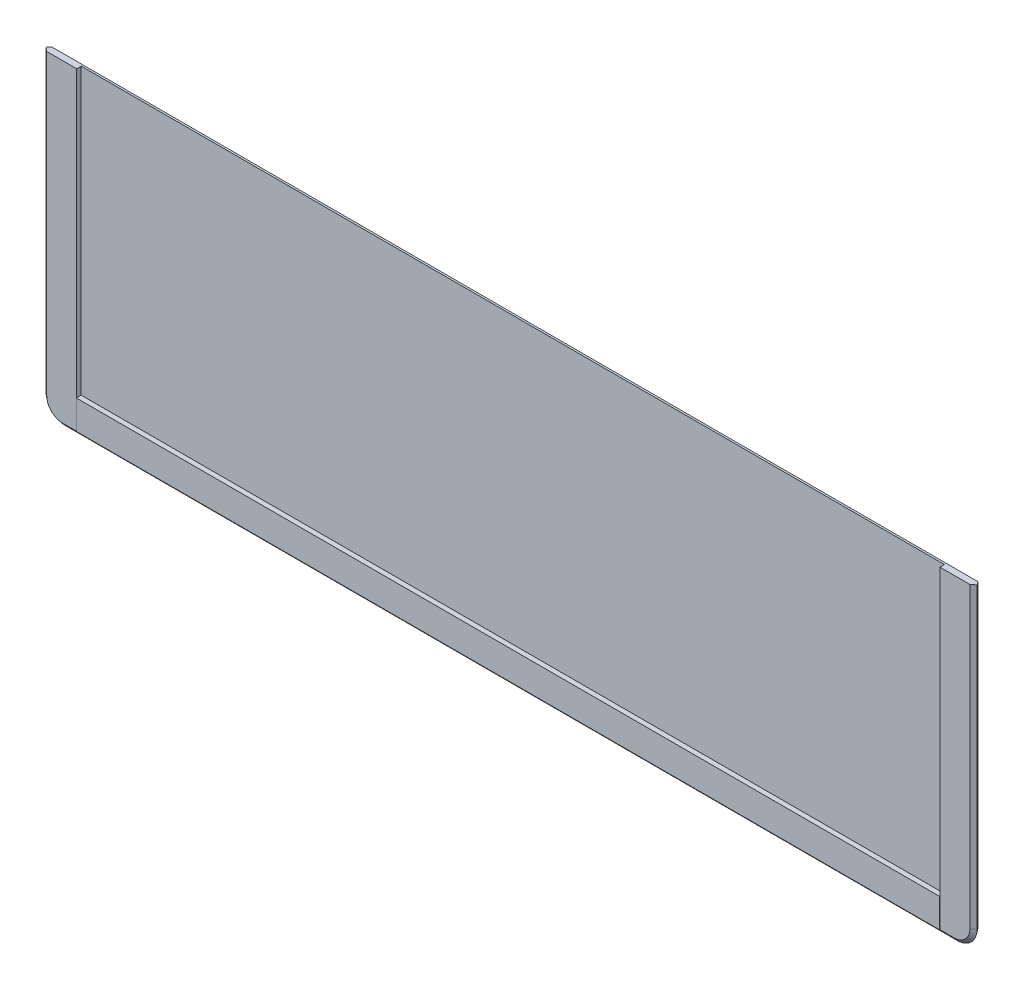
from build123d import *

# Parameters (mm, degrees)
BOSS_EXTRU_1_DEPTH      = 2
ENL_V_MAT_EXTRU_1_DEPTH = 1.4
ESQUISSE10_W            = 267.242852503
ESQUISSE10_H            = 8.975920375
BOSS_EXTRU_3_DEPTH      = 0.1
ESQUISSE11_W            = 12.5
ESQUISSE11_H            = 12.5
ENL_V_MAT_EXTRU_2_DEPTH = 0.1


with BuildPart() as part:
    # Esquisse1 → Boss.-Extru.1 (new body)
    with BuildSketch(Plane.XY):
        with BuildLine():
            Line((-154.451069542, 0), (-154.451069542, -92.3))
            ThreePointArc((-154.451069542, -92.3), (-152.107923791, -97.956854249), (-146.451069542, -100.3))
            Line((-146.451069542, -100.3), (129.548930458, -100.3))
            ThreePointArc((129.548930458, -100.3), (135.205784708, -97.956854249), (137.548930458, -92.3))
            Line((137.548930458, -92.3), (137.548930458, 0))
            Line((137.548930458, 0), (-154.451069542, 0))
        make_face()
    extrude(amount=BOSS_EXTRU_1_DEPTH)

    # Enlèvement de matière-Balayage3: sweep along a path in Esquisse3
    with BuildLine(Plane(origin=(0, 0, 0), x_dir=(-1, 0, 0), z_dir=(0, 0, -1))) as enl_vement_de_mati_re_balayage3_path:
        Line((154.451069542, 0.2), (154.451069542, -92.3))
        ThreePointArc((154.451069542, -92.3), (152.107923791, -97.956854249), (146.451069542, -100.3))
        Line((146.451069542, -100.3), (-129.548930458, -100.3))
        ThreePointArc((-129.548930458, -100.3), (-135.205784708, -97.956854249), (-137.548930458, -92.3))
        Line((-137.548930458, -92.3), (-137.548930458, 0.2))
    # Esquisse9 → Enlèvement de matière-Balayage3 (sweep, cut)
    with BuildSketch(Plane(origin=(0, 0, 0), x_dir=(1, 0, 0), z_dir=(0, 1, 0))):
        with BuildLine():
            Line((135.67035671, -1), (134.446277084, -2))
            Line((134.446277084, -2), (136.182569378, -2))
            Line((136.182569378, -2), (147.673144552, -2))
            Line((147.673144552, -2), (147.673144552, 0))
            Line((147.673144552, 0), (134.956411872, 0))
            add(Edge.make_bspline(
                [(134.956411872, 0), (135.206323755, -0.279338228), (135.44542126, -0.617312994), (135.67035671, -1)],
                knots=[0, 0, 0, 0, 0.17887146, 0.17887146, 0.17887146, 0.17887146], degree=3))
        make_face()
    sweep(path=enl_vement_de_mati_re_balayage3_path.line, mode=Mode.SUBTRACT)

    # Esquisse5 → Enlèv. mat.-Extru.1 (cut)
    with BuildSketch(Plane.XY.offset(2)):
        with BuildLine():
            Line((124.926952048, -84.47802159), (124.926952048, 0))
            Line((124.926952048, 0), (-141.829091132, 0))
            Line((-141.829091132, 0), (-141.829091132, -84.47802159))
            ThreePointArc((-141.829091132, -84.47802159), (-140.950411475, -86.599341934), (-138.829091132, -87.47802159))
            Line((-138.829091132, -87.47802159), (121.926952048, -87.47802159))
            ThreePointArc((121.926952048, -87.47802159), (124.048272392, -86.599341934), (124.926952048, -84.47802159))
        make_face()
        with BuildLine():
            Line((-142.072495793, -88.221426251), (125.17035671, -88.221426251))
            Line((125.17035671, -88.221426251), (125.17035671, 0))
            Line((125.17035671, 0), (124.926952048, 0))
            Line((124.926952048, 0), (124.926952048, -84.47802159))
            ThreePointArc((124.926952048, -84.47802159), (124.048272392, -86.599341934), (121.926952048, -87.47802159))
            Line((121.926952048, -87.47802159), (-138.829091132, -87.47802159))
            ThreePointArc((-138.829091132, -87.47802159), (-140.950411475, -86.599341934), (-141.829091132, -84.47802159))
            Line((-141.829091132, -84.47802159), (-141.829091132, 0))
            Line((-141.829091132, 0), (-142.072495793, 0))
            Line((-142.072495793, 0), (-142.072495793, -88.221426251))
        make_face()
    extrude(amount=-ENL_V_MAT_EXTRU_1_DEPTH, mode=Mode.SUBTRACT)

    # Esquisse10 → Boss.-Extru.3 (add)
    with BuildSketch(Plane.XY.offset(2)):
        with Locations((-8.451069541, -92.709386439)):
            Rectangle(ESQUISSE10_W, ESQUISSE10_H)
    extrude(amount=BOSS_EXTRU_3_DEPTH)

    # Esquisse11 → Enlèv. mat.-Extru.2 (cut)
    with BuildSketch(Plane(origin=(0, 0, 0), x_dir=(-1, 0, 0), z_dir=(0, 0, -1))):
        with Locations((1.501069542, -55.671426251)):
            Rectangle(ESQUISSE11_W, ESQUISSE11_H)
        with Locations((1.501069542, -41.771426251)):
            Rectangle(ESQUISSE11_W, ESQUISSE11_H)
        with Locations((15.401069542, -41.771426251)):
            Rectangle(ESQUISSE11_W, ESQUISSE11_H)
        with Locations((15.401069542, -55.671426251)):
            Rectangle(ESQUISSE11_W, ESQUISSE11_H)
    extrude(amount=-ENL_V_MAT_EXTRU_2_DEPTH, mode=Mode.SUBTRACT)


solid = part.part
